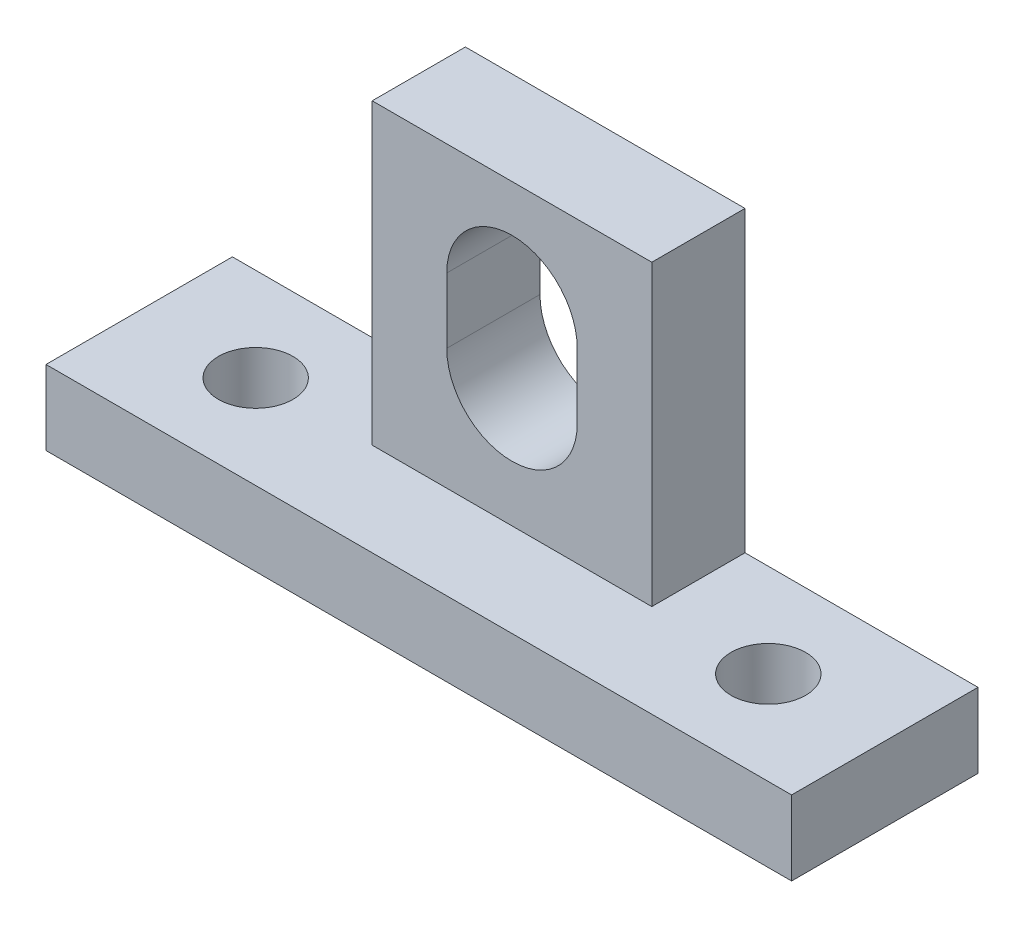
from build123d import *

# Parameters (mm, degrees)
RESSALTO_EXTRUS_O2_DEPTH = 10
ESBO_O5_R                = 2
CORTE_EXTRUS_O3_DEPTH    = 15
ESBO_O6_W                = 5
ESBO_O6_H                = 16
CORTE_EXTRUS_O4_DEPTH    = 15


with BuildPart() as part:
    # Esboço4 → Ressalto-extrusão2 (new body)
    with BuildSketch(Plane.XY):
        Polygon((-7.5, 20), (-7.5, 4), (-20, 4), (-20, 0), (20, 0), (20, 4), (7.5, 4), (7.5, 20), align=None)
        with BuildLine():
            Line((3.5, 14), (3.5, 10.5))
            ThreePointArc((3.5, 10.5), (0, 7), (-3.5, 10.5))
            Line((-3.5, 10.5), (-3.5, 14))
            ThreePointArc((-3.5, 14), (0, 17.5), (3.5, 14))
        make_face(mode=Mode.SUBTRACT)
    extrude(amount=RESSALTO_EXTRUS_O2_DEPTH)

    # Esboço5 → Corte-extrusão3 (cut)
    with BuildSketch(Plane(origin=(0, 4, 0), x_dir=(1, 0, 0), z_dir=(0, 1, 0))):
        with Locations((-13.75, -5)):
            Circle(ESBO_O5_R)
        with Locations((13.75, -5)):
            Circle(ESBO_O5_R)
    extrude(amount=-CORTE_EXTRUS_O3_DEPTH, mode=Mode.SUBTRACT)

    # Esboço6 → Corte-extrusão4 (cut)
    with BuildSketch(Plane.ZY.offset(7.5)):
        with Locations((7.5, 12)):
            Rectangle(ESBO_O6_W, ESBO_O6_H)
    extrude(amount=-CORTE_EXTRUS_O4_DEPTH, mode=Mode.SUBTRACT)


solid = part.part
